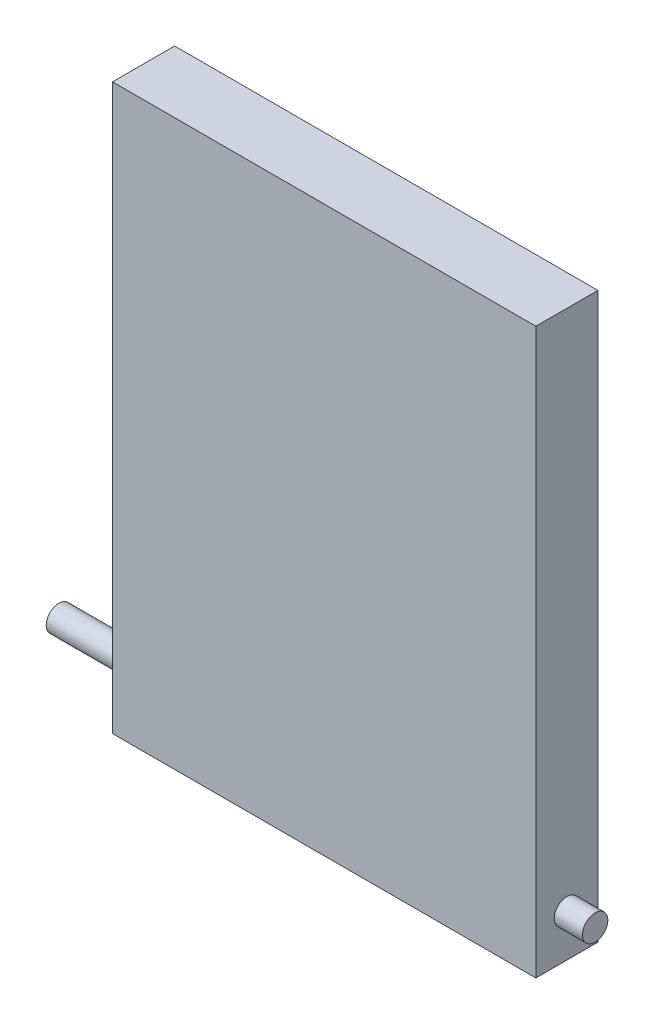
from build123d import *

# Parameters (mm, degrees)
ESQUISSE1_W           = 150
ESQUISSE1_H           = 200
EXTRUSION1_DEPTH      = 22
ESQUISSE2_R           = 4.5
EXTRUSION2_DEPTH      = 30
EXTRUSION2_DEPTH_BACK = 160


with BuildPart() as part:
    # Esquisse1 → Extrusion1 (new body)
    with BuildSketch(Plane.XY):
        with Locations((75, 100)):
            Rectangle(ESQUISSE1_W, ESQUISSE1_H)
    extrude(amount=EXTRUSION1_DEPTH)

    # Esquisse2 → Extrusion2 (add, two sides)
    with BuildSketch(Plane.ZY) as extrusion2_sk:
        with Locations((11, 15)):
            Circle(ESQUISSE2_R)
    extrude(amount=EXTRUSION2_DEPTH)
    extrude(extrusion2_sk.sketch, amount=-EXTRUSION2_DEPTH_BACK)


solid = part.part
